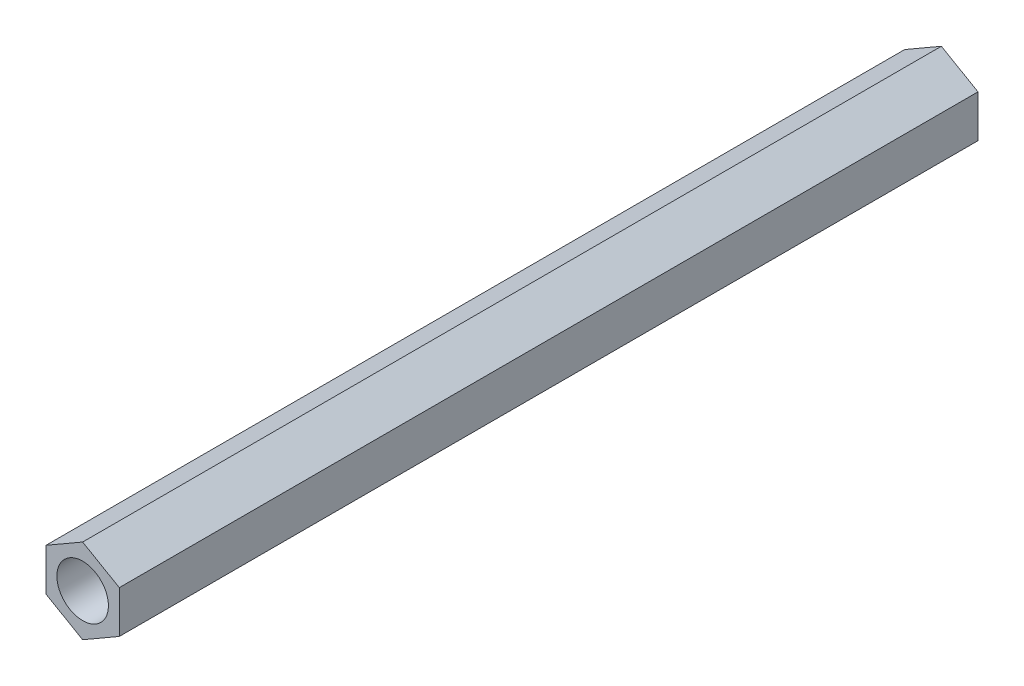
from build123d import *

# Parameters (mm, degrees)
SKETCH_1_R      = 1.5
EXTRUDE_1_DEPTH = 50


with BuildPart() as part:
    # 草图1 → 凸台-拉伸1 (new body)
    with BuildSketch(Plane.XY):
        Polygon((0, 2.463929225), (-2.133825302, 1.231964612), (-2.133825302, -1.231964612), (0, -2.463929225), (2.133825302, -1.231964612), (2.133825302, 1.231964612), align=None)
        Circle(SKETCH_1_R, mode=Mode.SUBTRACT)
    extrude(amount=EXTRUDE_1_DEPTH)


solid = part.part
